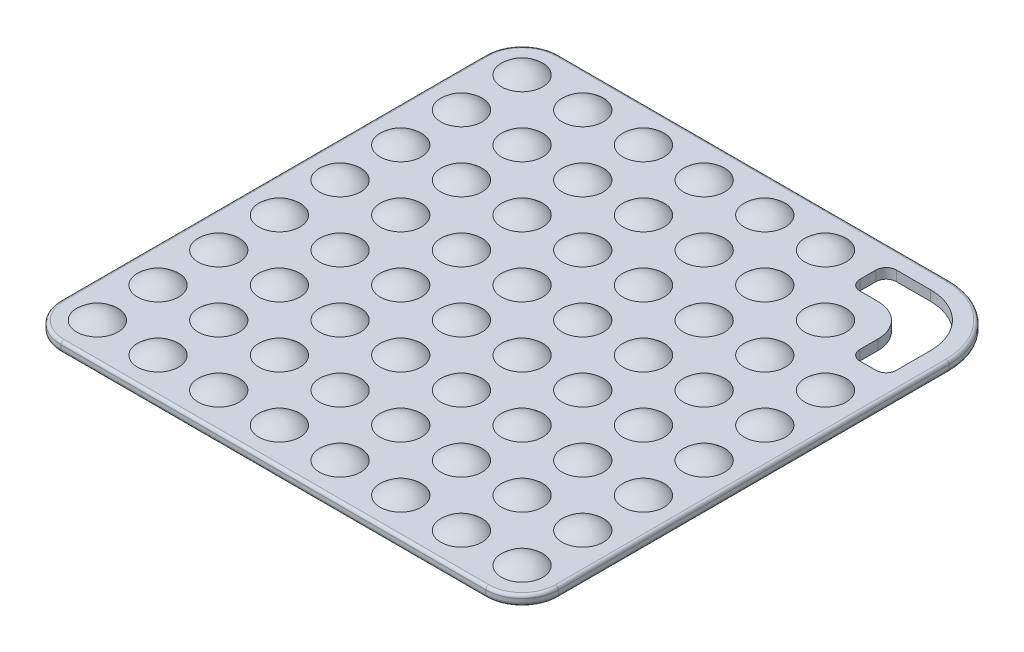
from build123d import *

# Parameters (mm, degrees)
BOSS_EXTRUDE1_DEPTH  = 5
FILLET1_R            = 1.5
LPATTERN1_COUNT      = 8
LPATTERN1_PITCH      = 30
LPATTERN1_COUNT_DIR2 = 8
LPATTERN1_PITCH_DIR2 = 30


with BuildPart() as part:
    # Sketch1 → Boss-Extrude1 (new body)
    with BuildSketch(Plane(origin=(0, 0, 0), x_dir=(1, 0, 0), z_dir=(0, 1, 0))):
        with BuildLine():
            Line((-105, -123), (105, -123))
            ThreePointArc((105, -123), (117.727922061, -117.727922061), (123, -105))
            Line((123, -105), (123, 88))
            ThreePointArc((123, 88), (112.748737342, 112.748737342), (88, 123))
            Line((88, 123), (-105, 123))
            ThreePointArc((-105, 123), (-117.727922061, 117.727922061), (-123, 105))
            Line((-123, 105), (-123, -105))
            ThreePointArc((-123, -105), (-117.727922061, -117.727922061), (-105, -123))
        make_face()
        with BuildLine():
            Line((88, 114), (71, 114))
            ThreePointArc((71, 114), (67.464466094, 112.535533906), (66, 109))
            Line((66, 109), (66, 101))
            ThreePointArc((66, 101), (67.464466094, 97.464466094), (71, 96))
            Line((71, 96), (80, 96))
            ThreePointArc((80, 96), (91.313708499, 91.313708499), (96, 80))
            Line((96, 80), (96, 71))
            ThreePointArc((96, 71), (97.464466094, 67.464466094), (101, 66))
            Line((101, 66), (109, 66))
            ThreePointArc((109, 66), (112.535533906, 67.464466094), (114, 71))
            Line((114, 71), (114, 88))
            ThreePointArc((114, 88), (106.384776311, 106.384776311), (88, 114))
        make_face(mode=Mode.SUBTRACT)
    extrude(amount=BOSS_EXTRUDE1_DEPTH)

    # Fillet1
    fillet1_edges = [part.edges().sort_by_distance(p)[0] for p in [
        (-8.5, 0, -123),
        (112.748737342, 0, -112.748737342),
        (123, 0, 8.5),
        (117.727922061, 0, 117.727922061),
        (112.748737342, 5, -112.748737342),
        (-8.5, 5, -123),
        (-117.727922061, 5, -117.727922061),
        (-123, 5, 0),
        (-117.727922061, 5, 117.727922061),
        (0, 5, 123),
        (117.727922061, 5, 117.727922061),
        (0, 0, 123),
        (123, 5, 8.5),
        (-117.727922061, 0, 117.727922061),
        (-123, 0, 0),
        (-117.727922061, 0, -117.727922061),
    ]]
    fillet(fillet1_edges, radius=FILLET1_R)

    # Sketch4 → Revolve1 (revolve)
    with BuildSketch(Plane.XY.offset(105)):
        with BuildLine():
            Line((-105, 9), (-105, 5))
            Line((-105, 5), (-115.198039027, 5))
            ThreePointArc((-115.198039027, 5), (-110.477225575, 7.964240044), (-105, 9))
        make_face()
    revolve1 = revolve(axis=Axis((-105, 9, 105), (0, -1, 0)))

    # LPattern1: Revolve1 8 × 8, 3 skipped
    with Locations(*[(i * LPATTERN1_PITCH, 0, -j * LPATTERN1_PITCH_DIR2) for i in range(LPATTERN1_COUNT) for j in range(LPATTERN1_COUNT_DIR2) if (i, j) not in ((0, 0), (6, 7), (7, 6), (7, 7))]):
        add(revolve1)


solid = part.part
